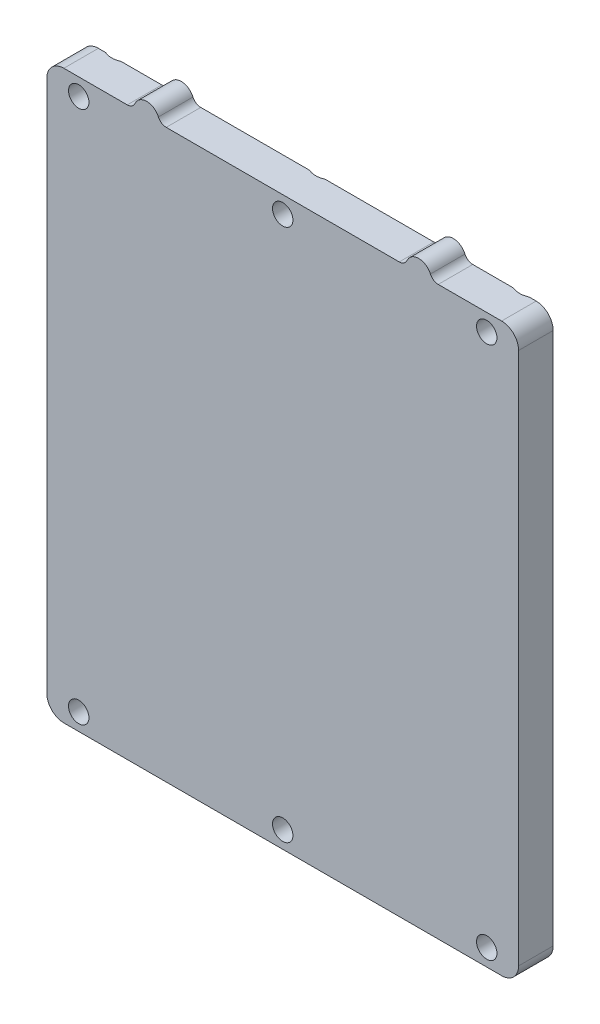
from build123d import *

# Parameters (mm, degrees)
SKETCH1_W                                       = 55.5
SKETCH1_H                                       = 66.7
BOSS_EXTRUDE1_DEPTH                             = 4.064
CSK_FOR_M2_FLAT_HEAD_MACHINE_SCREW3_D           = 2.4
CSK_FOR_M2_FLAT_HEAD_MACHINE_SCREW3_CSINK_D     = 4.4
CSK_FOR_M2_FLAT_HEAD_MACHINE_SCREW3_CSINK_ANGLE = 90
FILLET1_R                                       = 2
BOSS_EXTRUDE3_DEPTH                             = 4.064
FILLET2_R                                       = 1


with BuildPart() as part:
    # Sketch1 → Boss-Extrude1 (new body)
    with BuildSketch(Plane.XY):
        with Locations((27.75, 33.35)):
            Rectangle(SKETCH1_W, SKETCH1_H)
    extrude(amount=BOSS_EXTRUDE1_DEPTH)

    # CSK for M2 Flat Head Machine Screw3 (through all)
    with Locations(Plane(origin=(2.783474674, 10.392611329, 0), x_dir=(1, 0, 0), z_dir=(0, 0, -1))):
        with Locations((0.966525326, -54.307388671), (24.966525326, -54.307388671), (48.966525326, -54.307388671), (0.966525326, 8.392611329), (24.966525326, 8.392611329), (48.966525326, 8.392611329)):
            CounterSinkHole(CSK_FOR_M2_FLAT_HEAD_MACHINE_SCREW3_D / 2, CSK_FOR_M2_FLAT_HEAD_MACHINE_SCREW3_CSINK_D / 2, counter_sink_angle=CSK_FOR_M2_FLAT_HEAD_MACHINE_SCREW3_CSINK_ANGLE)

    # Fillet1
    fillet1_edges = [part.edges().sort_by_distance(p)[0] for p in [
        (0, 66.7, 2.032),
        (55.5, 66.7, 2.032),
        (55.5, 0, 2.032),
        (0, 0, 2.032),
    ]]
    fillet(fillet1_edges, radius=FILLET1_R)

    # Sketch7 → Boss-Extrude3 (add, through all)
    with BuildSketch(Plane.XY.offset(4.064)):
        with BuildLine():
            Line((10.25, 66.7), (13.25, 66.7))
            ThreePointArc((13.25, 66.7), (11.75, 68.2), (10.25, 66.7))
        make_face()
        with BuildLine():
            Line((42.25, 66.7), (45.25, 66.7))
            ThreePointArc((45.25, 66.7), (43.75, 68.2), (42.25, 66.7))
        make_face()
    extrude(amount=-BOSS_EXTRUDE3_DEPTH)

    # Fillet2
    fillet2_edges = [part.edges().sort_by_distance(p)[0] for p in [
        (10.25, 66.7, 2.032),
        (13.25, 66.7, 2.032),
        (42.25, 66.7, 2.032),
        (45.25, 66.7, 2.032),
    ]]
    fillet(fillet2_edges, radius=FILLET2_R)


solid = part.part
